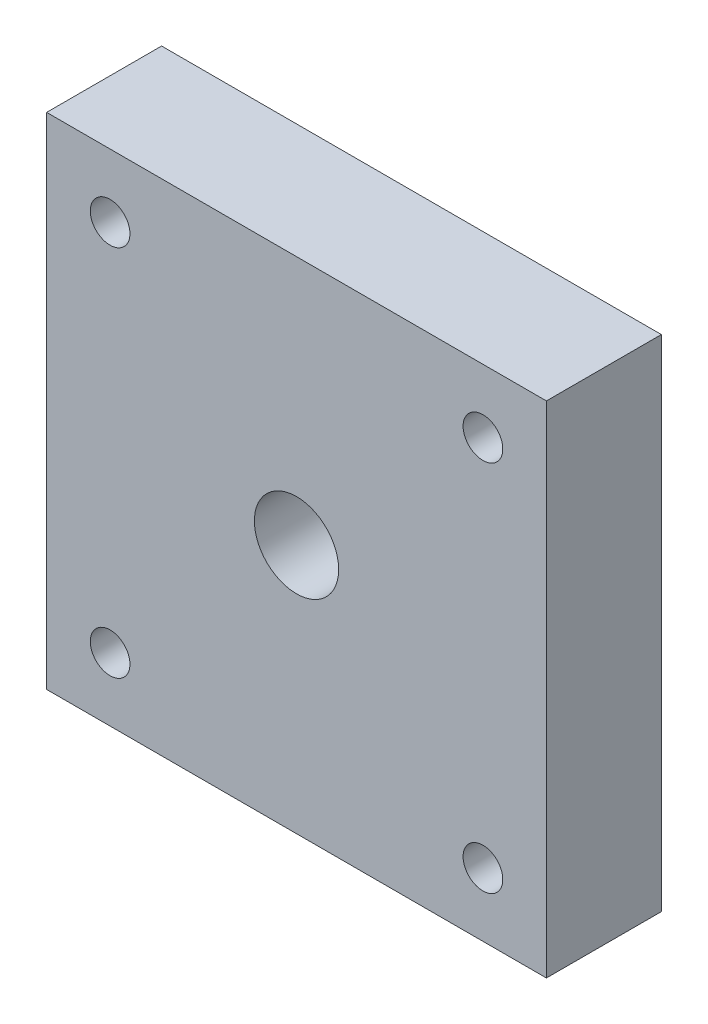
from build123d import *

# Parameters (mm, degrees)
SKETCH1_W               = 50
SKETCH1_H               = 50
BOSS_EXTRUDE1_DEPTH     = 11.5
SKETCH2_R               = 1.984375
CUT_EXTRUDE1_DEPTH      = 12.5
MIRROR2_COPY_1_SKETCH_R = 1.984375
MIRROR2_COPY_1_DEPTH    = 12.5
SKETCH3_R               = 4.2164
CUT_EXTRUDE2_DEPTH      = 12.5


with BuildPart() as part:
    # Sketch1 → Boss-Extrude1 (new body)
    with BuildSketch(Plane.XY):
        Rectangle(SKETCH1_W, SKETCH1_H)
    extrude(amount=BOSS_EXTRUDE1_DEPTH)

    # Sketch2 → Cut-Extrude1 (cut, through all)
    with BuildSketch(Plane.XY.offset(11.5)):
        with Locations((-18.65, 18.65)):
            Circle(SKETCH2_R)
    cut_extrude1 = extrude(amount=-CUT_EXTRUDE1_DEPTH, mode=Mode.SUBTRACT)

    # Mirror1: Cut-Extrude1 across plane
    add(cut_extrude1.mirror(Plane.ZX), mode=Mode.SUBTRACT)

    # Mirror2: Cut-Extrude1 across plane
    add(cut_extrude1.mirror(Plane(origin=(0, 0, 0), x_dir=(0, 0, 1), z_dir=(1, 0, 0))), mode=Mode.SUBTRACT)

    # Mirror2 copy 1 sketch → Mirror2 copy 1 (cut, through all)
    with BuildSketch(Plane(origin=(0, 0, 11.5), x_dir=(-1, 0, 0), z_dir=(0, 0, 1))):
        with Locations((-18.65, 18.65)):
            Circle(MIRROR2_COPY_1_SKETCH_R)
    extrude(amount=-MIRROR2_COPY_1_DEPTH, mode=Mode.SUBTRACT)

    # Sketch3 → Cut-Extrude2 (cut, through all)
    with BuildSketch(Plane.XY.offset(11.5)):
        Circle(SKETCH3_R)
    extrude(amount=-CUT_EXTRUDE2_DEPTH, mode=Mode.SUBTRACT)


solid = part.part
